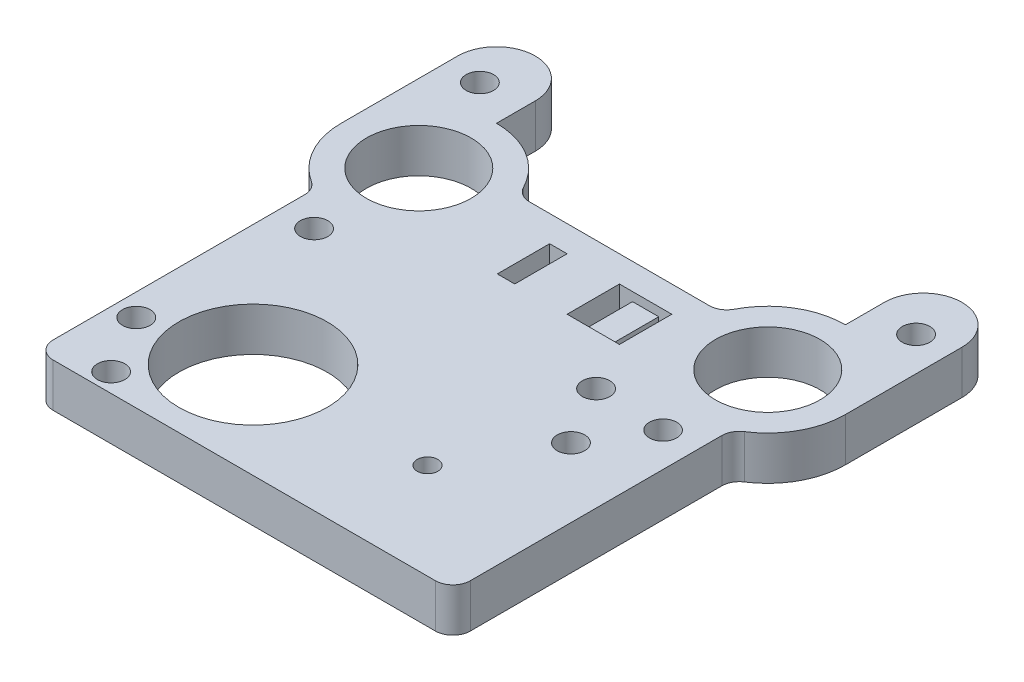
from build123d import *

# Parameters (mm, degrees)
BOSS_EXTRUDE2_DEPTH = 6.35
SKETCH6_W           = 2.54
SKETCH6_H           = 7.62
SKETCH6_W_2         = 1.905
CUT_EXTRUDE3_DEPTH  = 6.35
SKETCH7_R           = 10.795
SKETCH7_R_2         = 1.5
CUT_EXTRUDE4_DEPTH  = 6.35
SKETCH10_R          = 7.62
CUT_EXTRUDE6_DEPTH  = 6.35
SKETCH11_W          = 3.81
SKETCH11_H          = 7.62
CUT_EXTRUDE7_DEPTH  = 1.27
SKETCH8_R           = 2
SKETCH8_R_2         = 1.989430384
CUT_EXTRUDE8_DEPTH  = 6.35
SKETCH12_R          = 2
CUT_EXTRUDE9_DEPTH  = 6.35


with BuildPart() as part:
    # Sketch3 → Boss-Extrude2 (new body)
    with BuildSketch(Plane(origin=(0, 0, 0), x_dir=(1, 0, 0), z_dir=(0, 1, 0))):
        with BuildLine():
            Line((-27.819999986, -50.8), (-16.461471842, -50.8))
            Line((-16.461471842, -50.8), (4.000849576, -50.8))
            Line((4.000849576, -50.8), (23.297417358, -50.8))
            Line((23.297417358, -50.8), (27.819999986, -50.8))
            ThreePointArc((27.819999986, -50.8), (29.61605121, -50.056051224), (30.359999986, -48.26))
            Line((30.359999986, -48.26), (30.359999986, -11.643560444))
            ThreePointArc((30.359999986, -11.643560444), (30.670062071, -10.427428504), (31.524548724, -9.508207119))
            ThreePointArc((31.524548724, -9.508207119), (35.329369206, -5.415138673), (36.709999986, 0))
            Line((36.709999986, 0), (36.709999986, 16.964999979))
            ThreePointArc((36.709999986, 16.964999979), (31.054999993, 22.619999972), (25.4, 16.964999979))
            Line((25.4, 16.964999979), (25.4, 11.309999986))
            ThreePointArc((25.4, 11.309999986), (19.514906714, 9.658249153), (15.348771474, 5.185451262))
            ThreePointArc((15.348771474, 5.185451262), (14.413140747, 4.180950232), (13.091466391, 3.81))
            Line((13.091466391, 3.81), (-13.091466391, 3.81))
            ThreePointArc((-13.091466391, 3.81), (-14.413140747, 4.180950232), (-15.348771474, 5.185451262))
            ThreePointArc((-15.348771474, 5.185451262), (-19.514906714, 9.658249153), (-25.4, 11.309999986))
            Line((-25.4, 11.309999986), (-25.4, 16.964999979))
            ThreePointArc((-25.4, 16.964999979), (-31.054999993, 22.619999972), (-36.709999986, 16.964999979))
            Line((-36.709999986, 16.964999979), (-36.709999986, 0))
            ThreePointArc((-36.709999986, 0), (-35.329369206, -5.415138673), (-31.524548724, -9.508207119))
            ThreePointArc((-31.524548724, -9.508207119), (-30.670062071, -10.427428504), (-30.359999986, -11.643560444))
            Line((-30.359999986, -11.643560444), (-30.359999986, -48.26))
            ThreePointArc((-30.359999986, -48.26), (-29.61605121, -50.056051224), (-27.819999986, -50.8))
        make_face()
    extrude(amount=BOSS_EXTRUDE2_DEPTH)

    # Sketch6 → Cut-Extrude3 (cut)
    with BuildSketch(Plane(origin=(0, 6.35, 0), x_dir=(1, 0, 0), z_dir=(0, 1, 0))):
        with Locations((-5.08, -3.81)):
            Rectangle(SKETCH6_W, SKETCH6_H)
        with Locations((4.7625, -3.81)):
            Rectangle(SKETCH6_W_2, SKETCH6_H)
        with Locations((10.4775, -3.81)):
            Rectangle(SKETCH6_W_2, SKETCH6_H)
    extrude(amount=-CUT_EXTRUDE3_DEPTH, mode=Mode.SUBTRACT)

    # Sketch7 → Cut-Extrude4 (cut)
    with BuildSketch(Plane(origin=(0, 6.35, 0), x_dir=(1, 0, 0), z_dir=(0, 1, 0))):
        with Locations((-12.7, -36.83)):
            Circle(SKETCH7_R)
        with Locations((12.7, -36.83)):
            Circle(SKETCH7_R_2)
    extrude(amount=-CUT_EXTRUDE4_DEPTH, mode=Mode.SUBTRACT)

    # Sketch10 → Cut-Extrude6 (cut)
    with BuildSketch(Plane(origin=(0, 6.35, 0), x_dir=(1, 0, 0), z_dir=(0, 1, 0))):
        with Locations((-25.4, 0)):
            Circle(SKETCH10_R)
        with Locations((25.4, 0)):
            Circle(SKETCH10_R)
    extrude(amount=-CUT_EXTRUDE6_DEPTH, mode=Mode.SUBTRACT)

    # Sketch11 → Cut-Extrude7 (cut)
    with BuildSketch(Plane(origin=(0, 6.35, 0), x_dir=(1, 0, 0), z_dir=(0, 1, 0))):
        with Locations((7.62, -3.81)):
            Rectangle(SKETCH11_W, SKETCH11_H)
    extrude(amount=-CUT_EXTRUDE7_DEPTH, mode=Mode.SUBTRACT)

    # Sketch8 → Cut-Extrude8 (cut)
    with BuildSketch(Plane(origin=(0, 6.35, 0), x_dir=(1, 0, 0), z_dir=(0, 1, 0))):
        with Locations((-31.75, 15.24)):
            Circle(SKETCH8_R)
        with Locations((-25.4, -15.24)):
            Circle(SKETCH8_R)
        with Locations((25.4, -15.24)):
            Circle(SKETCH8_R_2)
        with Locations((31.75, 15.24)):
            Circle(SKETCH8_R)
    extrude(amount=-CUT_EXTRUDE8_DEPTH, mode=Mode.SUBTRACT)

    # Sketch12 → Cut-Extrude9 (cut)
    with BuildSketch(Plane(origin=(0, 6.35, 0), x_dir=(1, 0, 0), z_dir=(0, 1, 0))):
        with Locations((15.301414721, -14.889872981)):
            Circle(SKETCH12_R)
        with Locations((20.301414721, -23.550127019)):
            Circle(SKETCH12_R)
        with Locations((-22.133830064, -48.050127019)):
            Circle(SKETCH12_R)
        with Locations((-27.133830064, -39.389872981)):
            Circle(SKETCH12_R)
    extrude(amount=-CUT_EXTRUDE9_DEPTH, mode=Mode.SUBTRACT)


solid = part.part
